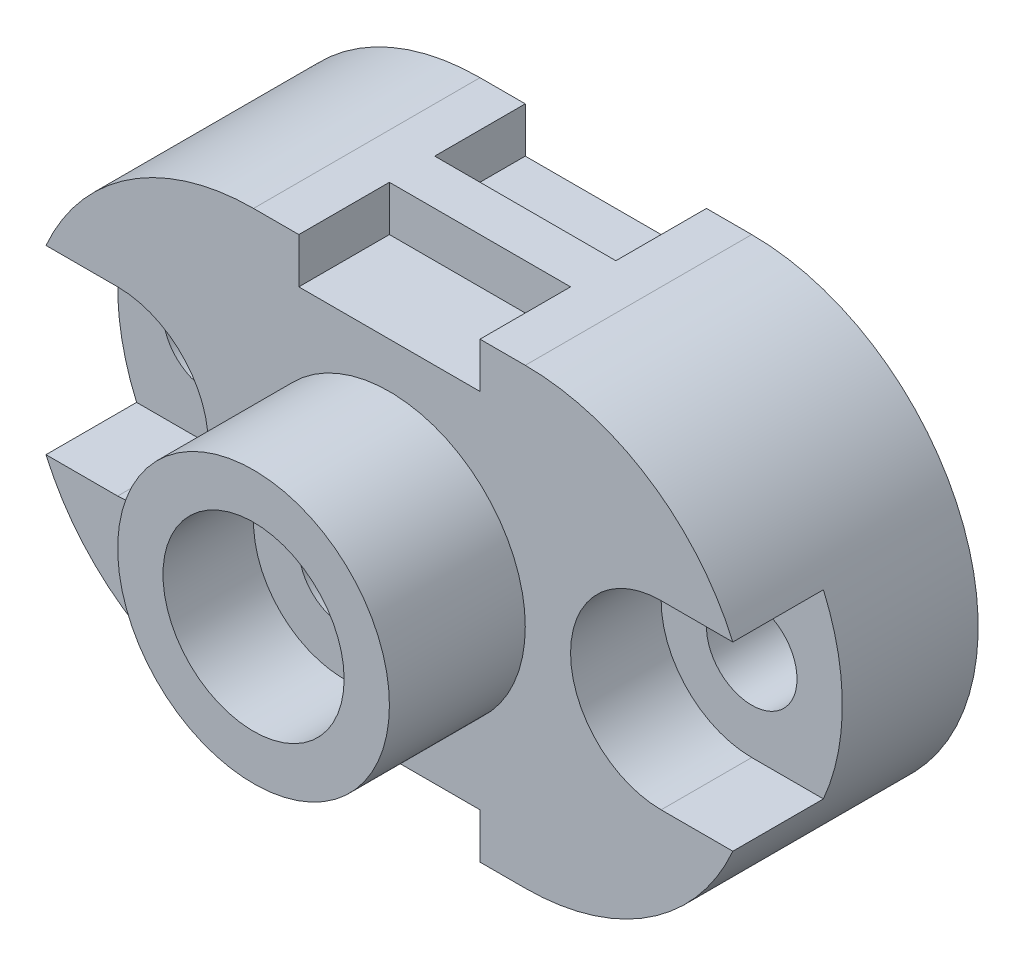
from build123d import *

# Parameters (mm, degrees)
BOSS_EXTRUDE1_DEPTH = 50
SKETCH2_R           = 10
CUT_EXTRUDE1_DEPTH  = 50
SKETCH3_R           = 30
BOSS_EXTRUDE2_DEPTH = 30
SKETCH4_R           = 20
CUT_EXTRUDE2_DEPTH  = 20
SKETCH5_R           = 10
CUT_EXTRUDE3_DEPTH  = 20
SKETCH6_W           = 40
SKETCH6_H           = 10
CUT_EXTRUDE4_DEPTH  = 20
SKETCH7_W           = 40
SKETCH7_H           = 10
CUT_EXTRUDE5_DEPTH  = 20
SKETCH8_W           = 40
SKETCH8_H           = 10
CUT_EXTRUDE6_DEPTH  = 20
SKETCH9_W           = 40
SKETCH9_H           = 10
CUT_EXTRUDE7_DEPTH  = 20
SKETCH10_R          = 10
CUT_EXTRUDE8_DEPTH  = 60
SKETCH11_R          = 10
CUT_EXTRUDE9_DEPTH  = 20


with BuildPart() as part:
    # Sketch1 → Boss-Extrude1 (new body)
    with BuildSketch(Plane.XY):
        with BuildLine():
            Line((0, 50), (60, 50))
            ThreePointArc((60, 50), (110, 0), (60, -50))
            Line((60, -50), (0, -50))
            ThreePointArc((0, -50), (-50, 0), (0, 50))
        make_face()
    extrude(amount=BOSS_EXTRUDE1_DEPTH)

    # Sketch2 → Cut-Extrude1 (cut)
    with BuildSketch(Plane.XY.offset(50)):
        with Locations((30, 0)):
            Circle(SKETCH2_R)
    extrude(amount=-CUT_EXTRUDE1_DEPTH, mode=Mode.SUBTRACT)

    # Sketch3 → Boss-Extrude2 (add)
    with BuildSketch(Plane.XY.offset(50)):
        with Locations((30, 0)):
            Circle(SKETCH3_R)
    extrude(amount=BOSS_EXTRUDE2_DEPTH)

    # Sketch4 → Cut-Extrude2 (cut)
    with BuildSketch(Plane.XY.offset(80)):
        with Locations((30, 0)):
            Circle(SKETCH4_R)
    extrude(amount=-CUT_EXTRUDE2_DEPTH, mode=Mode.SUBTRACT)

    # Sketch5 → Cut-Extrude3 (cut)
    with BuildSketch(Plane(origin=(0, 0, 50), x_dir=(-1, 0, 0), z_dir=(0, 0, -1))):
        with Locations((-30, 0)):
            Circle(SKETCH5_R)
    extrude(amount=-CUT_EXTRUDE3_DEPTH, mode=Mode.SUBTRACT)

    # Sketch6 → Cut-Extrude4 (cut)
    with BuildSketch(Plane.XY.offset(50)):
        with Locations((30, 45)):
            Rectangle(SKETCH6_W, SKETCH6_H)
    extrude(amount=-CUT_EXTRUDE4_DEPTH, mode=Mode.SUBTRACT)

    # Sketch7 → Cut-Extrude5 (cut)
    with BuildSketch(Plane(origin=(0, 0, 0), x_dir=(-1, 0, 0), z_dir=(0, 0, -1))):
        with Locations((-30, 45)):
            Rectangle(SKETCH7_W, SKETCH7_H)
    extrude(amount=-CUT_EXTRUDE5_DEPTH, mode=Mode.SUBTRACT)

    # Sketch8 → Cut-Extrude6 (cut)
    with BuildSketch(Plane.XY.offset(50)):
        with Locations((30, -45)):
            Rectangle(SKETCH8_W, SKETCH8_H)
    extrude(amount=-CUT_EXTRUDE6_DEPTH, mode=Mode.SUBTRACT)

    # Sketch9 → Cut-Extrude7 (cut)
    with BuildSketch(Plane(origin=(0, 0, 0), x_dir=(-1, 0, 0), z_dir=(0, 0, -1))):
        with Locations((-30, -45)):
            Rectangle(SKETCH9_W, SKETCH9_H)
    extrude(amount=-CUT_EXTRUDE7_DEPTH, mode=Mode.SUBTRACT)

    # Sketch10 → Cut-Extrude8 (cut)
    with BuildSketch(Plane.XY.offset(50)):
        with Locations((-30, 0)):
            Circle(SKETCH10_R)
        with Locations((90, 0)):
            Circle(SKETCH10_R)
    extrude(amount=-CUT_EXTRUDE8_DEPTH, mode=Mode.SUBTRACT)

    # Sketch11 → Cut-Extrude9 (cut)
    with BuildSketch(Plane.XY.offset(50)):
        with BuildLine():
            ThreePointArc((-30, -20), (-10, 0), (-30, 20))
            Line((-30, 20), (-45.82575695, 20))
            ThreePointArc((-45.82575695, 20), (-50, 0), (-45.82575695, -20))
            Line((-45.82575695, -20), (-30, -20))
        make_face()
        with Locations((-30, 0)):
            Circle(SKETCH11_R, mode=Mode.SUBTRACT)
        with BuildLine():
            Line((105.82575695, 20), (90, 20))
            ThreePointArc((90, 20), (70, 0), (90, -20))
            Line((90, -20), (105.82575695, -20))
            ThreePointArc((105.82575695, -20), (110, 0), (105.82575695, 20))
        make_face()
        with Locations((90, 0)):
            Circle(SKETCH11_R, mode=Mode.SUBTRACT)
    extrude(amount=-CUT_EXTRUDE9_DEPTH, mode=Mode.SUBTRACT)


solid = part.part
